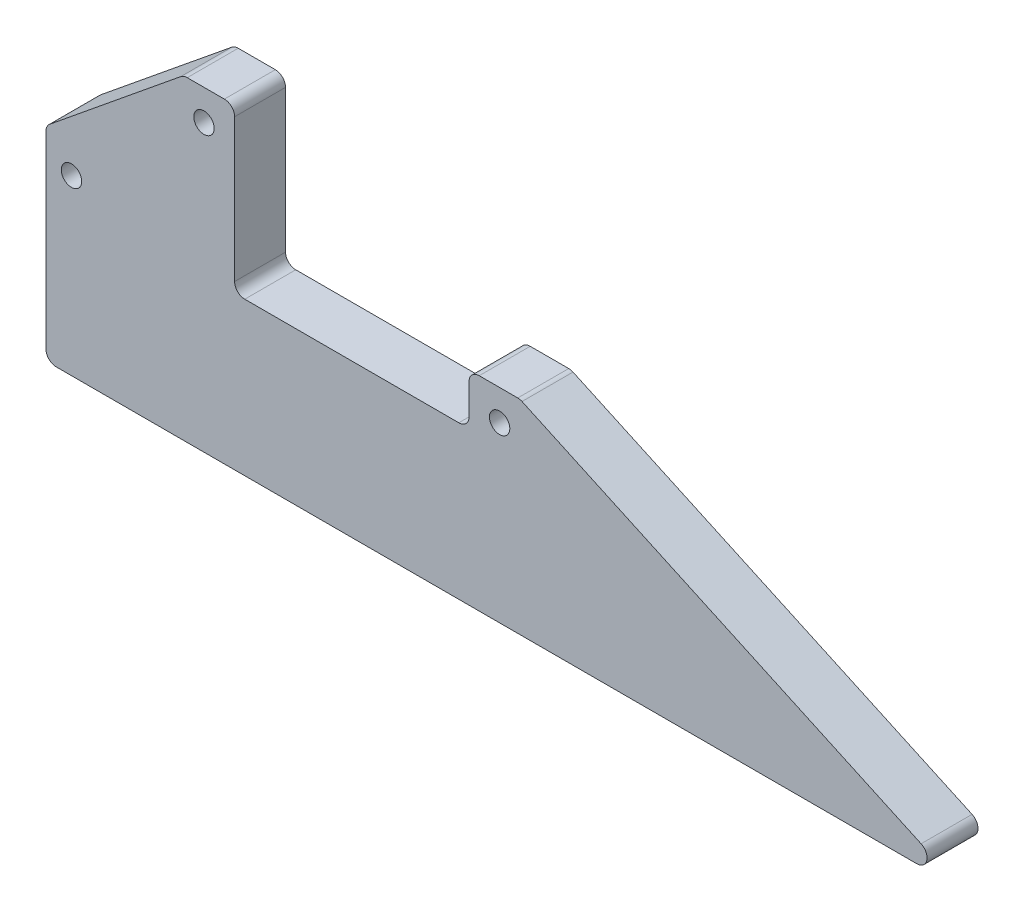
from build123d import *

# Parameters (mm, degrees)
BOSS_EXTRUDE1_DEPTH      = 10
F_4_0_4_DIAMETER_HOLE1_D = 4
FILLET2_R                = 2


with BuildPart() as part:
    # Sketch1 → Boss-Extrude1 (new body)
    with BuildSketch(Plane.XY):
        Polygon((-87, 40), (0, 0), (-180, 0), (-180, 40), (-153, 62), (-143, 62), (-143, 30), (-97, 30), (-97, 40), align=None)
    extrude(amount=BOSS_EXTRUDE1_DEPTH)

    # Ø4.0 (4) Diameter Hole1 (through all)
    with Locations(Plane.XY.offset(10)):
        with Locations((-149, 56), (-91, 34), (-175, 34)):
            Hole(F_4_0_4_DIAMETER_HOLE1_D / 2)

    # Fillet2
    fillet2_edges = [part.edges().sort_by_distance(p)[0] for p in [
        (-153, 62, 5),
        (-143, 62, 5),
        (-143, 30, 5),
        (-97, 30, 5),
        (-97, 40, 5),
        (-87, 40, 5),
        (0, 0, 5),
        (-180, 0, 5),
        (-180, 40, 5),
    ]]
    fillet(fillet2_edges, radius=FILLET2_R)


solid = part.part
